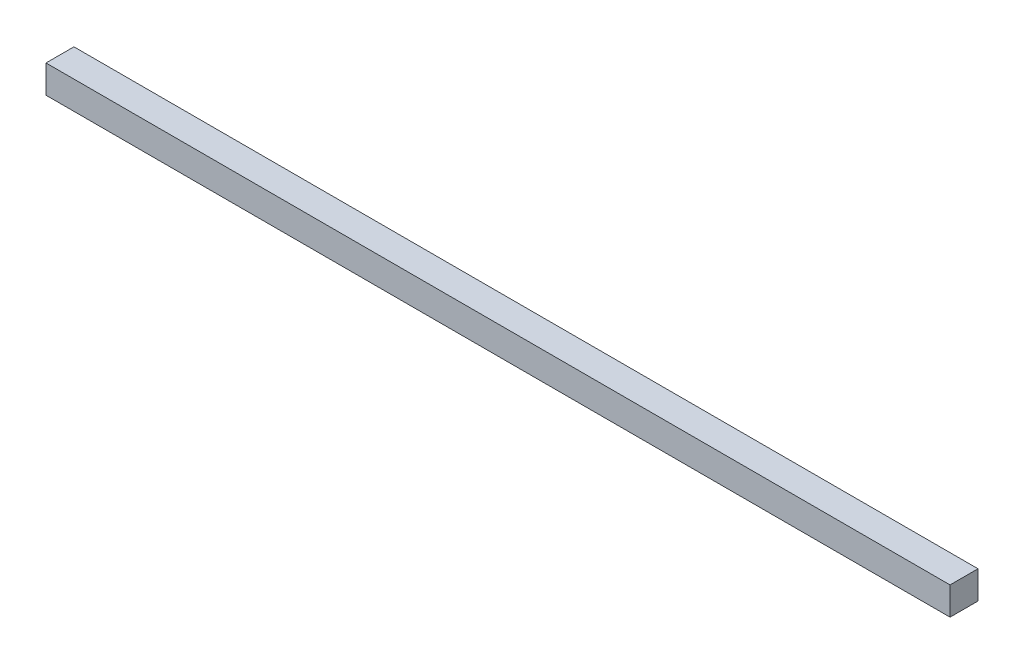
from build123d import *

# Parameters (mm, degrees)
SKETCH1_W           = 9.525
SKETCH1_H           = 9.525
BOSS_EXTRUDE1_DEPTH = 307.975


with BuildPart() as part:
    # Sketch1 → Boss-Extrude1 (new body)
    with BuildSketch(Plane(origin=(0, 0, 0), x_dir=(0, 0, -1), z_dir=(1, 0, 0))):
        with Locations((4.7625, 4.7625)):
            Rectangle(SKETCH1_W, SKETCH1_H)
    extrude(amount=-BOSS_EXTRUDE1_DEPTH)


solid = part.part
